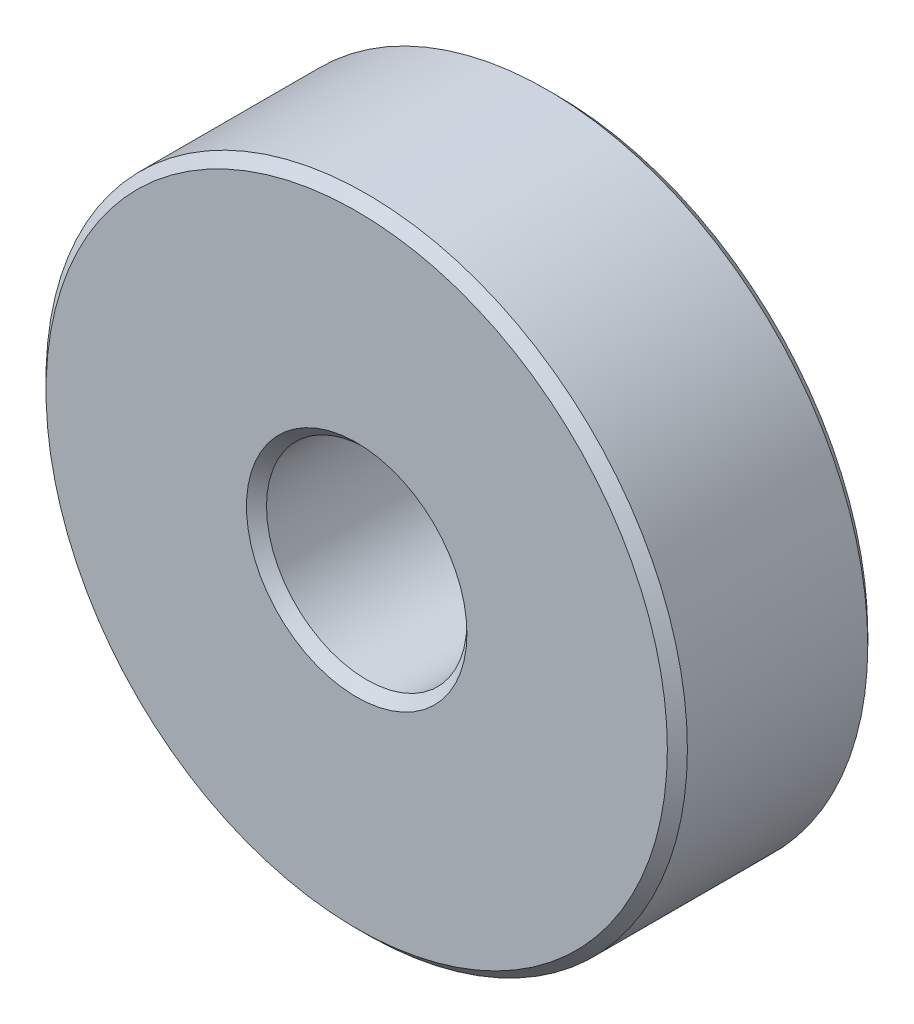
from build123d import *

# Parameters (mm, degrees)
SKETCH1_R           = 8
SKETCH1_R_2         = 2.5
BOSS_EXTRUDE1_DEPTH = 2.5
CHAMFER1_SIZE       = 0.25


with BuildPart() as part:
    # Sketch1 → Boss-Extrude1 (new body, symmetric)
    with BuildSketch(Plane.XY):
        Circle(SKETCH1_R)
        Circle(SKETCH1_R_2, mode=Mode.SUBTRACT)
    extrude(amount=BOSS_EXTRUDE1_DEPTH, both=True)

    # Chamfer1
    chamfer1_edges = [part.edges().sort_by_distance(p)[0] for p in [
        (-8, 0, -2.5),
        (-8, 0, 2.5),
        (-2.5, 0, -2.5),
        (-2.5, 0, 2.5),
    ]]
    chamfer(chamfer1_edges, length=CHAMFER1_SIZE)


solid = part.part
